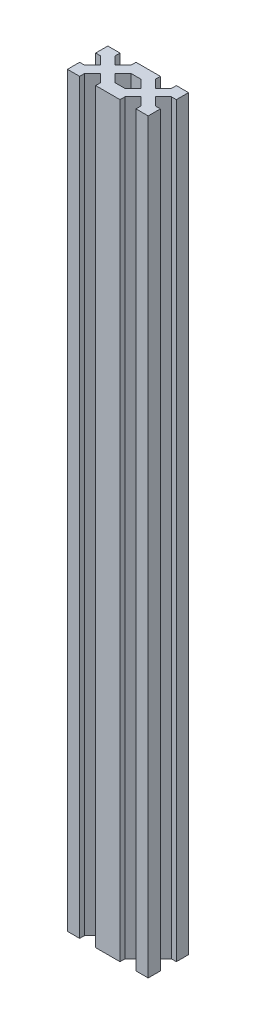
from build123d import *

# Parameters (mm, degrees)
BOSS_EXTRU_2_DEPTH = 370


with BuildPart() as part:
    # Esquisse1_3 → Boss.-Extru.2 (new body)
    with BuildSketch(Plane(origin=(0, 0, 0), x_dir=(1, 0, 0), z_dir=(0, 1, 0))):
        Polygon((-6.035533906, 17.5), (-10, 13.535533906), (-13.964466094, 17.5), (-13.964466094, 20), (-20, 20), (-20, 13.964466094), (-17.5, 13.964466094), (-13.535533906, 10), (-17.5, 6.035533906), (-20, 6.035533906), (-20, 0), (-13.964466094, 0), (-13.964466094, 2.5), (-10, 6.464466094), (-6.035533906, 2.5), (-6.035533906, 0), (6.035533906, 0), (6.035533906, 2.5), (10, 6.464466094), (13.964466094, 2.5), (13.964466094, 0), (20, 0), (20, 6.035533906), (17.5, 6.035533906), (13.535533906, 10), (17.5, 13.964466094), (20, 13.964466094), (20, 20), (13.964466094, 20), (13.964466094, 17.5), (10, 13.535533906), (6.035533906, 17.5), (6.035533906, 20), (-6.035533906, 20), align=None)
        Polygon((-6.464466094, 10), (-2.5, 13.964466094), (2.5, 13.964466094), (6.464466094, 10), (2.5, 6.035533906), (-2.5, 6.035533906), align=None, mode=Mode.SUBTRACT)
    extrude(amount=BOSS_EXTRU_2_DEPTH)


solid = part.part
